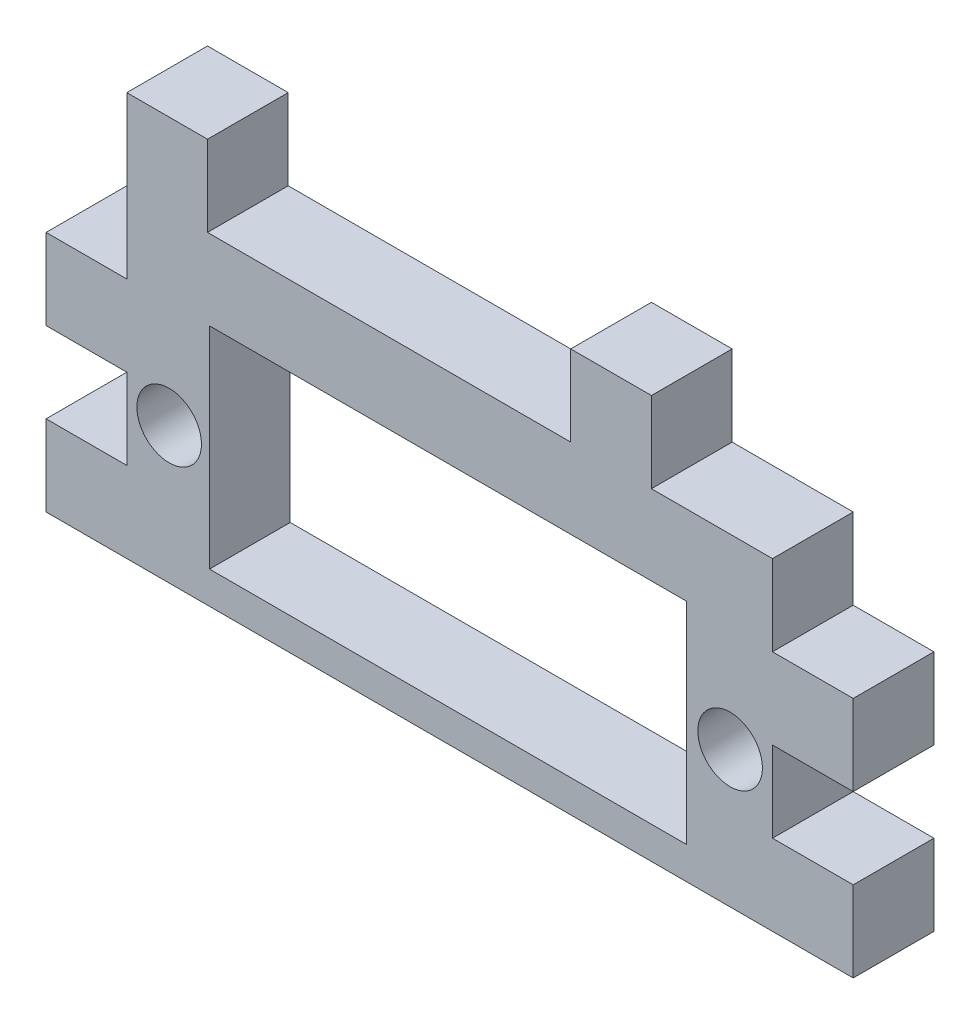
from build123d import *

# Parameters (mm, degrees)
ESQUISSE1_W             = 25
ESQUISSE1_H             = 25
BOSS_EXTRU_1_DEPTH      = 5
ESQUISSE3_W             = 5
ESQUISSE3_H             = 5
ENL_V_MAT_EXTRU_1_DEPTH = 5
ESQUISSE4_R             = 2
ESQUISSE4_W             = 29.55
ESQUISSE4_H             = 13.05
ENL_V_MAT_EXTRU_2_DEPTH = 5
ESQUISSE5_W             = 5
ESQUISSE5_H             = 5
BOSS_EXTRU_2_DEPTH      = 5


with BuildPart() as part:
    # Esquisse1 → Boss.-Extru.1 (new body)
    with BuildSketch(Plane.XY):
        with Locations((-53.521610088, -25.407575758)):
            Rectangle(ESQUISSE1_W, ESQUISSE1_H)
    boss_extru_1 = extrude(amount=BOSS_EXTRU_1_DEPTH)

    # Esquisse3 → Enlèv. mat.-Extru.1 (cut)
    with BuildSketch(Plane(origin=(0, 0, 0), x_dir=(-1, 0, 0), z_dir=(0, 0, -1))):
        Polygon((66.021610088, -12.907575758), (66.021610088, -17.907575758), (46.021610088, -17.907575758), (46.021610088, -22.907575758), (41.021610088, -22.907575758), (41.021610088, -12.907575758), align=None)
        with Locations((43.521610088, -30.407575758)):
            Rectangle(ESQUISSE3_W, ESQUISSE3_H)
    enl_v_mat_extru_1 = extrude(amount=-ENL_V_MAT_EXTRU_1_DEPTH, mode=Mode.SUBTRACT)

    # Symétrie1: Boss.-Extru.1, Enlèv. mat.-Extru.1 across plane
    add(boss_extru_1.mirror(Plane(origin=(-66.021610088, -12.907575758, 5), x_dir=(0, 0, 1), z_dir=(1, 0, 0))))
    add(enl_v_mat_extru_1.mirror(Plane(origin=(-66.021610088, -12.907575758, 5), x_dir=(0, 0, 1), z_dir=(1, 0, 0))), mode=Mode.SUBTRACT)

    # Esquisse4 → Enlèv. mat.-Extru.2 (cut)
    with BuildSketch(Plane(origin=(0, 0, 0), x_dir=(-1, 0, 0), z_dir=(0, 0, -1))):
        with Locations((83.396610088, -29.457575758)):
            Circle(ESQUISSE4_R)
        with Locations((48.646610088, -29.457575758)):
            Circle(ESQUISSE4_R)
        with Locations((66.121610088, -29.382575758)):
            Rectangle(ESQUISSE4_W, ESQUISSE4_H)
    extrude(amount=-ENL_V_MAT_EXTRU_2_DEPTH, mode=Mode.SUBTRACT)

    # Esquisse5 → Boss.-Extru.2 (add)
    with BuildSketch(Plane(origin=(0, -17.907575758, 0), x_dir=(1, 0, 0), z_dir=(0, 1, 0))):
        with Locations((-83.521610088, -2.5)):
            Rectangle(ESQUISSE5_W, ESQUISSE5_H)
        with Locations((-56.021610088, -2.5)):
            Rectangle(ESQUISSE5_W, ESQUISSE5_H)
    extrude(amount=BOSS_EXTRU_2_DEPTH)


solid = part.part
